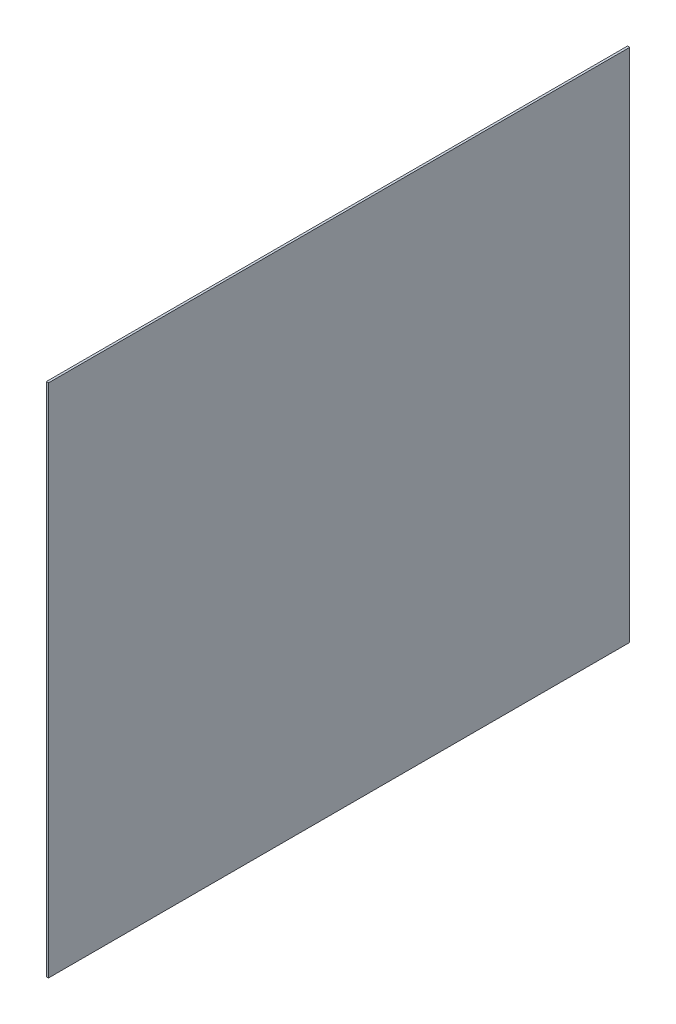
from build123d import *

# Parameters (mm, degrees)
SKETCH2_W = 412.496
SKETCH2_H = 365.76
PCB_DEPTH = 1.5875


with BuildPart() as part:
    # Sketch2 → PCB (new body)
    with BuildSketch(Plane(origin=(0, 0, 0), x_dir=(0, 0, -1), z_dir=(1, 0, 0))):
        with Locations((206.248, 182.88)):
            Rectangle(SKETCH2_W, SKETCH2_H)
    extrude(amount=PCB_DEPTH)


solid = part.part
